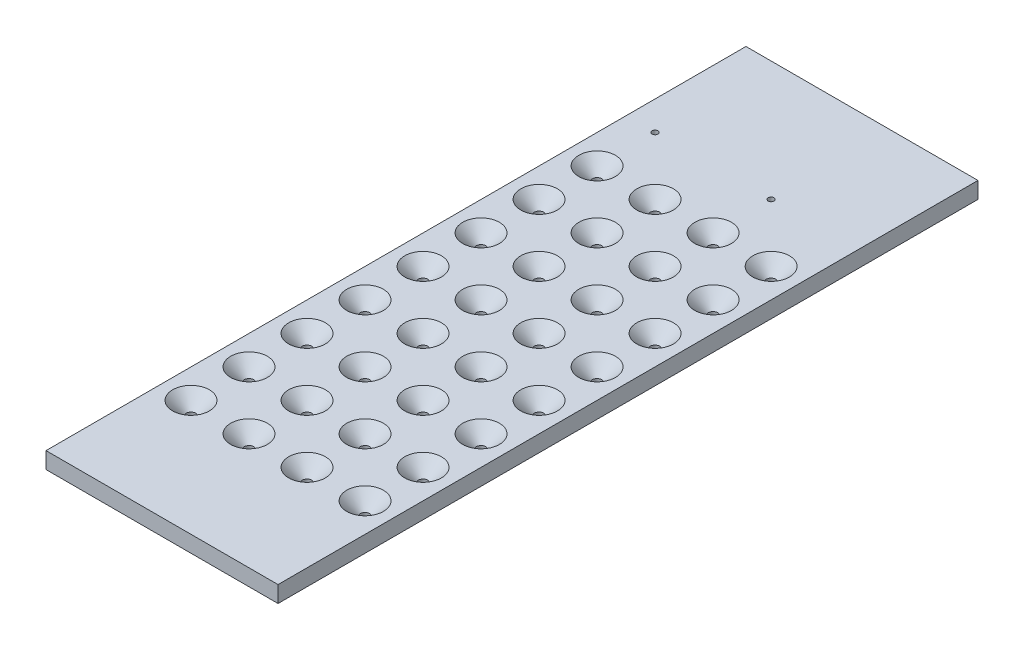
from build123d import *

# Parameters (mm, degrees)
ESQUISSE1_W             = 120
ESQUISSE1_H             = 362
BOSS_EXTRU_1_DEPTH      = 8.5
ESQUISSE2_R             = 2.5
ESQUISSE2_R_2           = 1.5
ENL_V_MAT_EXTRU_1_DEPTH = 9.5
CHANFREIN1_SIZE         = 7


with BuildPart() as part:
    # Esquisse1 → Boss.-Extru.1 (new body)
    with BuildSketch(Plane(origin=(0, 0, 0), x_dir=(1, 0, 0), z_dir=(0, 1, 0))):
        Rectangle(ESQUISSE1_W, ESQUISSE1_H)
    extrude(amount=-BOSS_EXTRU_1_DEPTH)

    # Esquisse2 → Enlèv. mat.-Extru.1 (cut, through all)
    with BuildSketch(Plane(origin=(0, 0, 0), x_dir=(1, 0, 0), z_dir=(0, 1, 0))):
        with Locations((-45, 89)):
            Circle(ESQUISSE2_R)
        with Locations((-45, 119)):
            Circle(ESQUISSE2_R_2)
        with Locations((15, 119)):
            Circle(ESQUISSE2_R_2)
        with Locations((-15, 89)):
            Circle(ESQUISSE2_R)
        with Locations((15, 89)):
            Circle(ESQUISSE2_R)
        with Locations((45, 89)):
            Circle(ESQUISSE2_R)
        with Locations((-15, 59)):
            Circle(ESQUISSE2_R)
        with Locations((15, 59)):
            Circle(ESQUISSE2_R)
        with Locations((45, 59)):
            Circle(ESQUISSE2_R)
        with Locations((-15, 29)):
            Circle(ESQUISSE2_R)
        with Locations((15, 29)):
            Circle(ESQUISSE2_R)
        with Locations((45, 29)):
            Circle(ESQUISSE2_R)
        with Locations((-15, -1)):
            Circle(ESQUISSE2_R)
        with Locations((15, -1)):
            Circle(ESQUISSE2_R)
        with Locations((45, -1)):
            Circle(ESQUISSE2_R)
        with Locations((-15, -31)):
            Circle(ESQUISSE2_R)
        with Locations((15, -31)):
            Circle(ESQUISSE2_R)
        with Locations((45, -31)):
            Circle(ESQUISSE2_R)
        with Locations((-15, -61)):
            Circle(ESQUISSE2_R)
        with Locations((15, -61)):
            Circle(ESQUISSE2_R)
        with Locations((45, -61)):
            Circle(ESQUISSE2_R)
        with Locations((-15, -91)):
            Circle(ESQUISSE2_R)
        with Locations((15, -91)):
            Circle(ESQUISSE2_R)
        with Locations((45, -91)):
            Circle(ESQUISSE2_R)
        with Locations((-15, -121)):
            Circle(ESQUISSE2_R)
        with Locations((15, -121)):
            Circle(ESQUISSE2_R)
        with Locations((45, -121)):
            Circle(ESQUISSE2_R)
        with Locations((-45, 59)):
            Circle(ESQUISSE2_R)
        with Locations((-45, 29)):
            Circle(ESQUISSE2_R)
        with Locations((-45, -1)):
            Circle(ESQUISSE2_R)
        with Locations((-45, -31)):
            Circle(ESQUISSE2_R)
        with Locations((-45, -61)):
            Circle(ESQUISSE2_R)
        with Locations((-45, -91)):
            Circle(ESQUISSE2_R)
        with Locations((-45, -121)):
            Circle(ESQUISSE2_R)
    extrude(amount=-ENL_V_MAT_EXTRU_1_DEPTH, mode=Mode.SUBTRACT)

    # Chanfrein1
    chanfrein1_edges = [part.edges().sort_by_distance(p)[0] for p in [
        (12.5, 0, 31),
        (42.5, 0, 31),
        (12.5, 0, 1),
        (-17.5, 0, 1),
        (42.5, 0, -29),
        (12.5, 0, -29),
        (-47.5, 0, 121),
        (-47.5, 0, -89),
        (12.5, 0, 121),
        (-17.5, 0, 121),
        (42.5, 0, 91),
        (12.5, 0, 91),
        (-17.5, 0, 61),
        (12.5, 0, 61),
        (42.5, 0, 61),
        (-17.5, 0, 91),
        (-47.5, 0, 31),
        (-47.5, 0, 61),
        (-47.5, 0, 91),
        (42.5, 0, 121),
        (-47.5, 0, -59),
        (-47.5, 0, -29),
        (-47.5, 0, 1),
        (-17.5, 0, -89),
        (12.5, 0, -89),
        (42.5, 0, -89),
        (-17.5, 0, -29),
        (42.5, 0, -59),
        (12.5, 0, -59),
        (-17.5, 0, -59),
        (42.5, 0, 1),
        (-17.5, 0, 31),
    ]]
    chamfer(chanfrein1_edges, length=CHANFREIN1_SIZE)


solid = part.part
